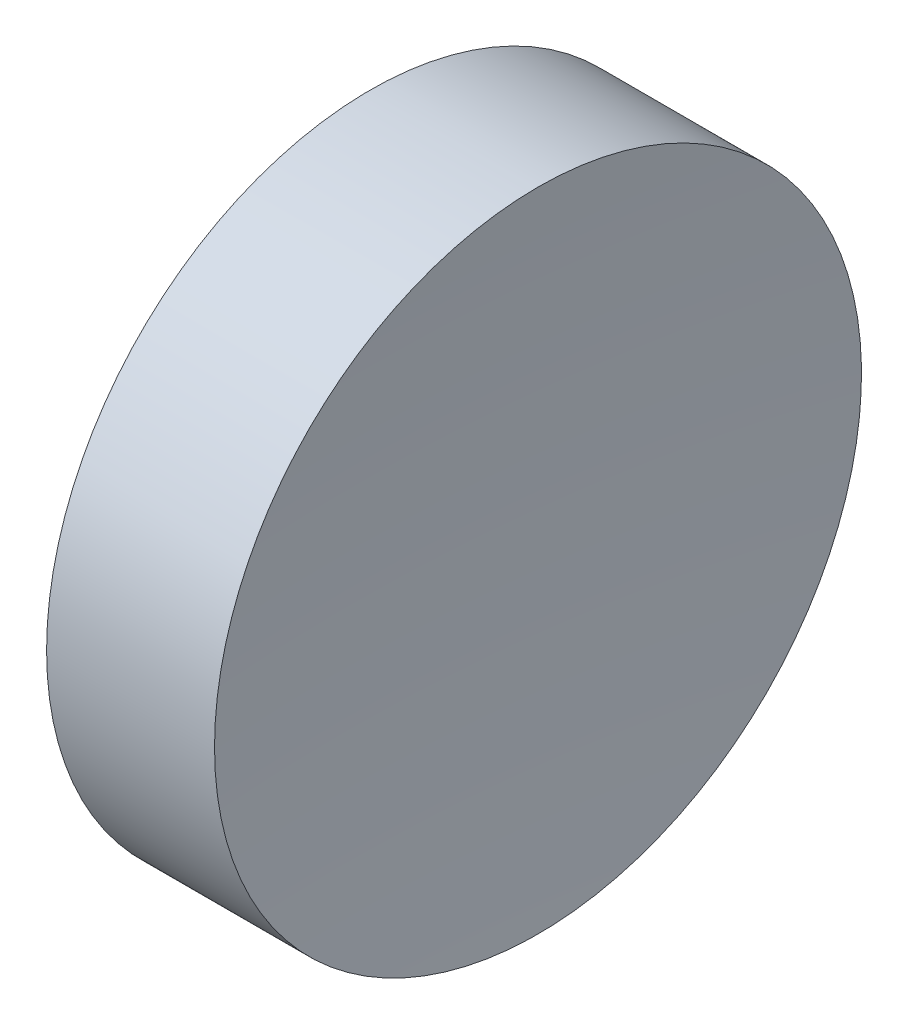
from build123d import *


with BuildPart() as part:
    # 草图1 → 旋转1 (revolve)
    with BuildSketch(Plane.XY):
        with BuildLine():
            Line((57.546327767, 34.689010562), (57.546327767, 40.939010562))
            Line((57.546327767, 40.939010562), (60.790842203, 40.939010562))
            ThreePointArc((60.790842203, 40.939010562), (60.607479854, 37.816401137), (60.546327908, 34.689010562))
            Line((60.546327908, 34.689010562), (57.546327767, 34.689010562))
        make_face()
    revolve(axis=Axis((54.492571501, 34.689010562, 0), (1, 0, 0)))


solid = part.part
